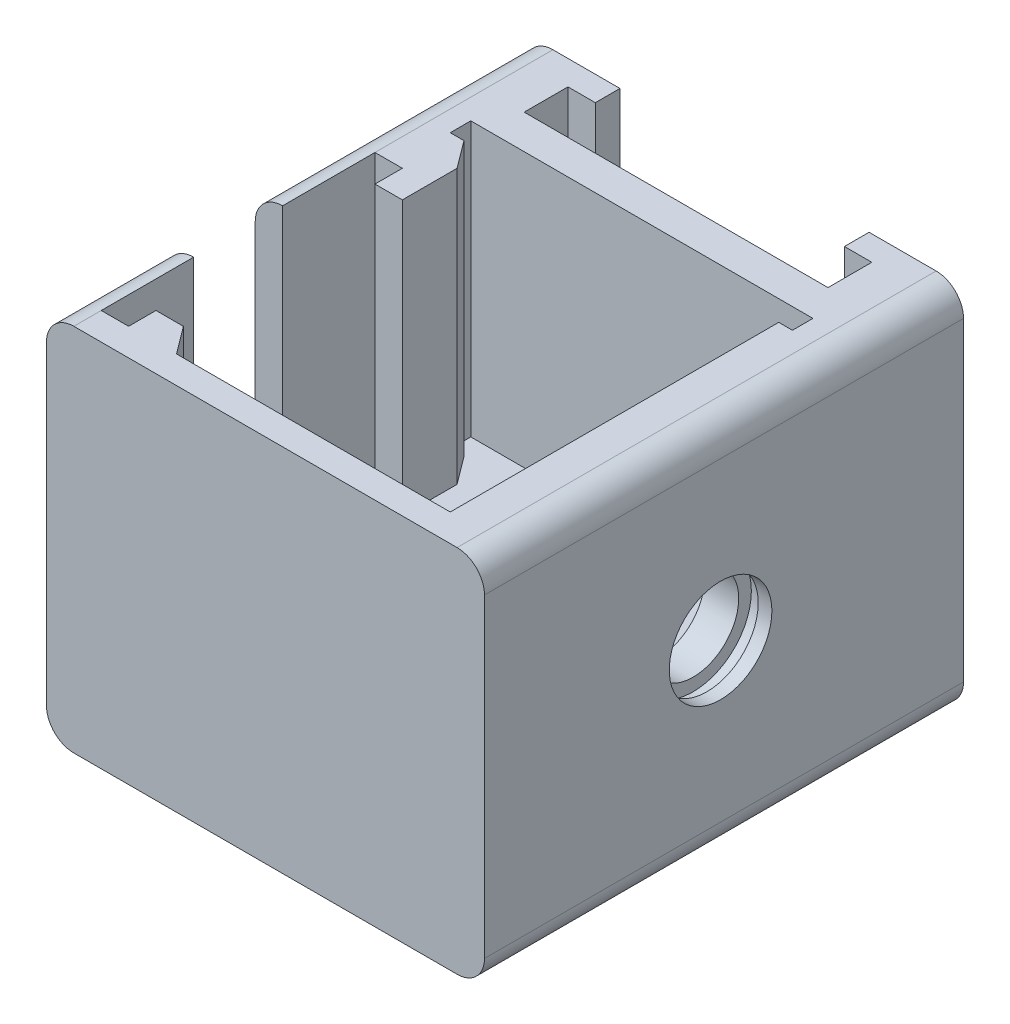
from build123d import *

# Parameters (mm, degrees)
SKETCH1_W               = 32
SKETCH1_H               = 27
BOSS_EXTRUDE1_DEPTH     = 35
FILLET1_R               = 2
CUT_EXTRUDE1_DEPTH      = 1
CUT_EXTRUDE1_DEPTH_BACK = 28
BOSS_EXTRUDE2_DEPTH     = 7
BOSS_EXTRUDE3_DEPTH     = 1.8
SKETCH5_W               = 2
SKETCH5_H               = 7
CUT_EXTRUDE2_DEPTH      = 33
CUT_EXTRUDE3_DEPTH      = 20
SKETCH7_W               = 2
SKETCH7_H               = 33
BOSS_EXTRUDE4_DEPTH     = 0.25
FILLET2_R               = 6
CUT_EXTRUDE5_DEPTH      = 4.5
SKETCH14_W              = 2.5
SKETCH14_H              = 20
CUT_EXTRUDE6_DEPTH      = 20
SKETCH16_W              = 2
SKETCH16_H              = 4
SKETCH16_H_2            = 2
BOSS_EXTRUDE5_DEPTH     = 20
BOSS_EXTRUDE6_DEPTH     = 20


with BuildPart() as part:
    # Sketch1 → Boss-Extrude1 (new body)
    with BuildSketch(Plane.XY):
        Rectangle(SKETCH1_W, SKETCH1_H)
    extrude(amount=BOSS_EXTRUDE1_DEPTH)

    # Fillet1
    fillet1_edges = [part.edges().sort_by_distance(p)[0] for p in [
        (16, -13.5, 17.5),
        (-16, -13.5, 17.5),
        (-16, 13.5, 17.5),
        (16, 13.5, 17.5),
    ]]
    fillet(fillet1_edges, radius=FILLET1_R)

    # Sketch2 → Cut-Extrude1 (cut, two sides)
    with BuildSketch(Plane.XZ.offset(13.5)) as cut_extrude1_sk:
        Polygon((-9.1, 0), (-9.1, 1.8), (-11.1, 1.8), (-11.1, 5), (11.1, 5), (11.1, 1.8), (9.1, 1.8), (9.1, 0), align=None)
    extrude(amount=CUT_EXTRUDE1_DEPTH, mode=Mode.SUBTRACT)
    extrude(cut_extrude1_sk.sketch, amount=-CUT_EXTRUDE1_DEPTH_BACK, mode=Mode.SUBTRACT)

    # Sketch3 → Boss-Extrude2 (add)
    with BuildSketch(Plane.XZ.offset(13.5)):
        Polygon((-9.1, 0), (-9.1, 1.8), (-11.1, 1.8), (-11.1, 5), (11.1, 5), (11.1, 1.8), (9.1, 1.8), (9.1, 0), align=None)
    extrude(amount=-BOSS_EXTRUDE2_DEPTH)

    # Sketch4 → Boss-Extrude3 (add)
    with BuildSketch(Plane(origin=(0, 0, 1.8), x_dir=(-1, 0, 0), z_dir=(0, 0, -1))):
        with BuildLine():
            Line((-9.1, 6.5), (-9.1, 5.5))
            ThreePointArc((-9.1, 5.5), (-8.85, 6), (-9.1, 6.5))
        make_face()
    boss_extrude3 = extrude(amount=BOSS_EXTRUDE3_DEPTH)

    # Mirror1: Boss-Extrude3 across plane
    add(boss_extrude3.mirror(Plane(origin=(0, 0, 0), x_dir=(0, 0, 1), z_dir=(1, 0, 0))))

    # Sketch5 → Cut-Extrude2 (cut)
    with BuildSketch(Plane(origin=(0, 0, 0), x_dir=(-1, 0, 0), z_dir=(0, 0, -1))):
        with Locations((0, -10)):
            Rectangle(SKETCH5_W, SKETCH5_H)
    extrude(amount=-CUT_EXTRUDE2_DEPTH, mode=Mode.SUBTRACT)

    # Sketch6 → Cut-Extrude3 (cut)
    with BuildSketch(Plane(origin=(0, 13.5, 0), x_dir=(1, 0, 0), z_dir=(0, 1, 0))):
        Polygon((-12.5, -7.5), (-12.5, -9), (-11.5, -9), (-11.5, -33), (11.5, -33), (11.5, -9), (12.5, -9), (12.5, -7.5), align=None)
    extrude(amount=-CUT_EXTRUDE3_DEPTH, mode=Mode.SUBTRACT)

    # Sketch7 → Boss-Extrude4 (add)
    with BuildSketch(Plane.XZ.offset(13.5)):
        with Locations((0, 16.5)):
            Rectangle(SKETCH7_W, SKETCH7_H)
    extrude(amount=-BOSS_EXTRUDE4_DEPTH)

    # Fillet2
    fillet2_edges = [part.edges().sort_by_distance(p)[0] for p in [
        (0, -13.25, 33),
    ]]
    fillet(fillet2_edges, radius=FILLET2_R)

    # Sketch9 → Cut-Revolve1 (revolve, cut)
    with BuildSketch(Plane(origin=(0, 0, 17.75), x_dir=(-1, 0, 0), z_dir=(0, 0, -1))):
        Polygon((-15, 4.25), (-14, 4.25), (-14, 3.325), (-11.5, 3.325), (-11.5, 0), (-16, 0), (-16, 3.75), (-15, 3.75), align=None)
    revolve(axis=Axis((16, 0, 17.75), (-1, 0, 0)), mode=Mode.SUBTRACT)

    # Sketch11 → Cut-Extrude5 (cut)
    with BuildSketch(Plane(origin=(-16, 0, 44), x_dir=(0, 0, -1), z_dir=(1, 0, 0))):
        with BuildLine():
            Line((24.25, 23), (24.25, 0))
            ThreePointArc((24.25, 0), (21, -3.25), (17.75, 0))
            Line((17.75, 0), (17.75, 23))
            ThreePointArc((17.75, 23), (21, 26.25), (24.25, 23))
        make_face()
    extrude(amount=CUT_EXTRUDE5_DEPTH, mode=Mode.SUBTRACT)

    # Sketch14 → Cut-Extrude6 (cut)
    with BuildSketch(Plane(origin=(0, 13.5, 0), x_dir=(1, 0, 0), z_dir=(0, 1, 0))):
        with Locations((-12.75, -23)):
            Rectangle(SKETCH14_W, SKETCH14_H)
    extrude(amount=-CUT_EXTRUDE6_DEPTH, mode=Mode.SUBTRACT)

    # Sketch16 → Boss-Extrude5 (add)
    with BuildSketch(Plane(origin=(0, 13.5, 0), x_dir=(1, 0, 0), z_dir=(0, 1, 0))):
        with Locations((-11, -13)):
            Rectangle(SKETCH16_W, SKETCH16_H)
        with Locations((-11, -32)):
            Rectangle(SKETCH16_W, SKETCH16_H_2)
    extrude(amount=-BOSS_EXTRUDE5_DEPTH)

    # Sketch20 → Boss-Extrude6 (add)
    with BuildSketch(Plane(origin=(0, 13.5, 0), x_dir=(1, 0, 0), z_dir=(0, 1, 0))):
        Polygon((-11.5, -9), (-10, -11), (-11.5, -11), align=None)
        Polygon((-10, -31), (-8.5, -33), (-10, -33), align=None)
    extrude(amount=-BOSS_EXTRUDE6_DEPTH)


solid = part.part
